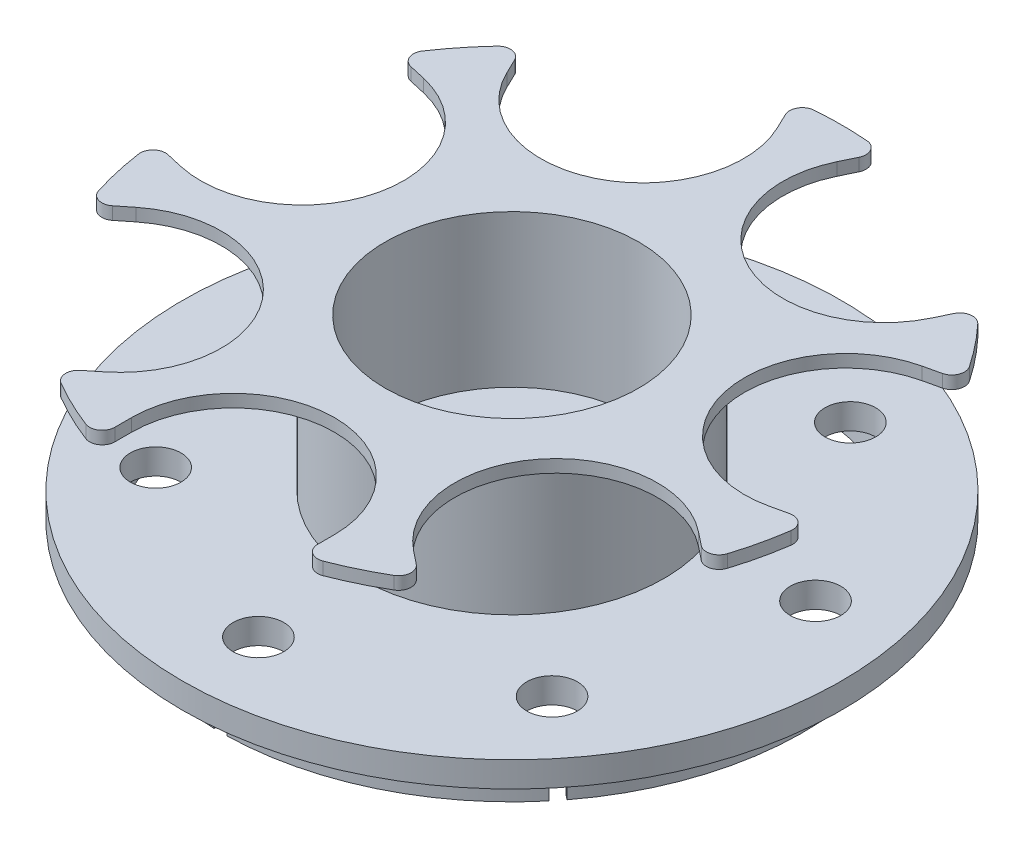
from build123d import *

# Parameters (mm, degrees)
SKETCH1_R           = 130
BOSS_EXTRUDE1_DEPTH = 10
CUT_EXTRUDE1_REACH  = 12
SKETCH2_R           = 35
SKETCH3_R           = 60
SKETCH3_R_2         = 50
BOSS_EXTRUDE2_DEPTH = 55
SKETCH4_R           = 130
SKETCH4_R_2         = 50
BOSS_EXTRUDE3_DEPTH = 5
SKETCH6_R           = 60
SKETCH6_R_2         = 45
BOSS_EXTRUDE4_DEPTH = 15
CUT_EXTRUDE3_DEPTH  = 5
CIRPATTERN1_COUNT   = 7
SKETCH10_R          = 115
SKETCH10_R_2        = 112
BOSS_EXTRUDE5_DEPTH = 15
SKETCH11_W          = 5
SKETCH11_H          = 25
CUT_EXTRUDE4_DEPTH  = 15
CIRPATTERN2_COUNT   = 7
SKETCH12_R          = 10
CUT_EXTRUDE5_DEPTH  = 10
CIRPATTERN3_COUNT   = 7
FILLET1_R           = 5


with BuildPart() as part:
    # Sketch1 → Boss-Extrude1 (new body)
    with BuildSketch(Plane(origin=(0, 0, 0), x_dir=(1, 0, 0), z_dir=(0, 1, 0))):
        Circle(SKETCH1_R)
    extrude(amount=BOSS_EXTRUDE1_DEPTH)

    # Sketch2 → Cut-Extrude1 (cut, up to next)
    with BuildSketch(Plane(origin=(0, 10, 0), x_dir=(1, 0, 0), z_dir=(0, 1, 0)), mode=Mode.PRIVATE) as cut_extrude1_sk1:
        Circle(SKETCH2_R)
    cut_extrude1_tool1 = extrude(cut_extrude1_sk1.sketch, amount=-CUT_EXTRUDE1_REACH, mode=Mode.PRIVATE) & part.part
    add(cut_extrude1_tool1.solids().sort_by_distance((0, 10, 0))[0], mode=Mode.SUBTRACT)

    # Sketch3 → Boss-Extrude2 (add)
    with BuildSketch(Plane(origin=(0, 10, 0), x_dir=(1, 0, 0), z_dir=(0, 1, 0))):
        Circle(SKETCH3_R)
        Circle(SKETCH3_R_2, mode=Mode.SUBTRACT)
    extrude(amount=BOSS_EXTRUDE2_DEPTH)

    # Sketch4 → Boss-Extrude3 (add)
    with BuildSketch(Plane(origin=(0, 65, 0), x_dir=(1, 0, 0), z_dir=(0, 1, 0))):
        Circle(SKETCH4_R)
        Circle(SKETCH4_R_2, mode=Mode.SUBTRACT)
    extrude(amount=BOSS_EXTRUDE3_DEPTH)

    # Sketch6 → Boss-Extrude4 (add)
    with BuildSketch(Plane.XZ):
        Circle(SKETCH6_R)
        Circle(SKETCH6_R_2, mode=Mode.SUBTRACT)
    extrude(amount=BOSS_EXTRUDE4_DEPTH)

    # Sketch8 → Cut-Extrude3 (cut)
    with BuildSketch(Plane(origin=(0, 70, 0), x_dir=(1, 0, 0), z_dir=(0, 1, 0))):
        with BuildLine():
            Line((40, -110), (40, -123.693168769))
            ThreePointArc((40, -123.693168769), (0, -130), (-40, -123.693168769))
            Line((-40, -123.693168769), (-40, -110))
            ThreePointArc((-40, -110), (0, -70), (40, -110))
        make_face()
    cut_extrude3 = extrude(amount=-CUT_EXTRUDE3_DEPTH, mode=Mode.SUBTRACT)

    # CirPattern1: Cut-Extrude3 ×7 about axis
    cirpattern1_axis = Axis((0, 0, 0), (0, 1, 0))
    for i in range(1, CIRPATTERN1_COUNT):
        add(cut_extrude3.rotate(cirpattern1_axis, i * 360 / CIRPATTERN1_COUNT), mode=Mode.SUBTRACT)

    # Sketch10 → Boss-Extrude5 (add)
    with BuildSketch(Plane.XZ):
        Circle(SKETCH10_R)
        Circle(SKETCH10_R_2, mode=Mode.SUBTRACT)
    extrude(amount=BOSS_EXTRUDE5_DEPTH)

    # Sketch11 → Cut-Extrude4 (cut)
    with BuildSketch(Plane.XZ.offset(15)):
        with Locations((0, 110)):
            Rectangle(SKETCH11_W, SKETCH11_H)
    cut_extrude4 = extrude(amount=-CUT_EXTRUDE4_DEPTH, mode=Mode.SUBTRACT)

    # CirPattern2: Cut-Extrude4 ×7 about axis
    cirpattern2_axis = Axis((0, 0, 0), (0, 1, 0))
    for i in range(1, CIRPATTERN2_COUNT):
        add(cut_extrude4.rotate(cirpattern2_axis, i * 360 / CIRPATTERN2_COUNT), mode=Mode.SUBTRACT)

    # Sketch12 → Cut-Extrude5 (cut)
    with BuildSketch(Plane(origin=(0, 10, 0), x_dir=(1, 0, 0), z_dir=(0, 1, 0))):
        with Locations((0, -100)):
            Circle(SKETCH12_R)
    cut_extrude5 = extrude(amount=-CUT_EXTRUDE5_DEPTH, mode=Mode.SUBTRACT)

    # CirPattern3: Cut-Extrude5 ×7 about axis
    cirpattern3_axis = Axis((0, 0, 0), (0, 1, 0))
    for i in range(1, CIRPATTERN3_COUNT):
        add(cut_extrude5.rotate(cirpattern3_axis, i * 360 / CIRPATTERN3_COUNT), mode=Mode.SUBTRACT)

    # Fillet1
    fillet1_edges = [part.edges().sort_by_distance(p)[0] for p in [
        (71.767621435, 67.5, 108.394688585),
        (121.646805584, 67.5, 45.848169988),
        (-40, 67.5, 123.693168769),
        (40, 67.5, 123.693168769),
        (-121.646805584, 67.5, 45.848169988),
        (-71.767621435, 67.5, 108.394688585),
        (-17.629699852, 67.5, -128.799043797),
        (-89.707209285, 67.5, -94.088344668),
        (-111.69108542, 67.5, -66.521435926),
        (-129.492760137, 67.5, 11.472797049),
        (129.492760137, 67.5, 11.472797049),
        (111.69108542, 67.5, -66.521435926),
        (89.707209285, 67.5, -94.088344668),
        (17.629699852, 67.5, -128.799043797),
    ]]
    fillet(fillet1_edges, radius=FILLET1_R)


solid = part.part
